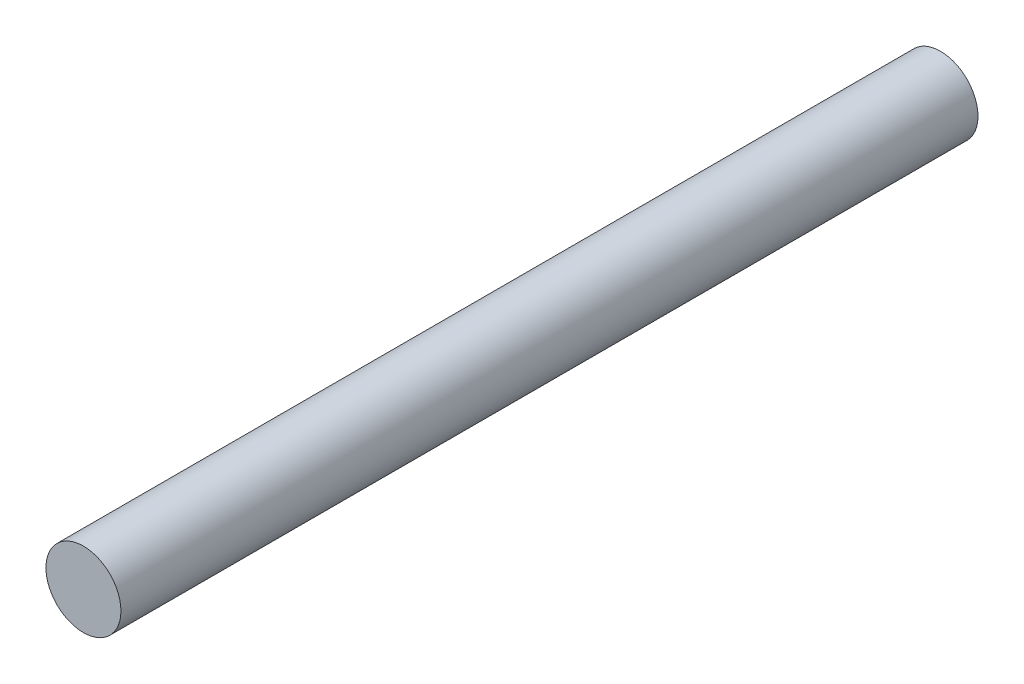
from build123d import *

# Parameters (mm, degrees)
CROQUIS1_R              = 1.75
SALIENTE_EXTRUIR1_DEPTH = 40


with BuildPart() as part:
    # Croquis1 → Saliente-Extruir1 (new body)
    with BuildSketch(Plane.XY):
        Circle(CROQUIS1_R)
    extrude(amount=SALIENTE_EXTRUIR1_DEPTH)


solid = part.part
